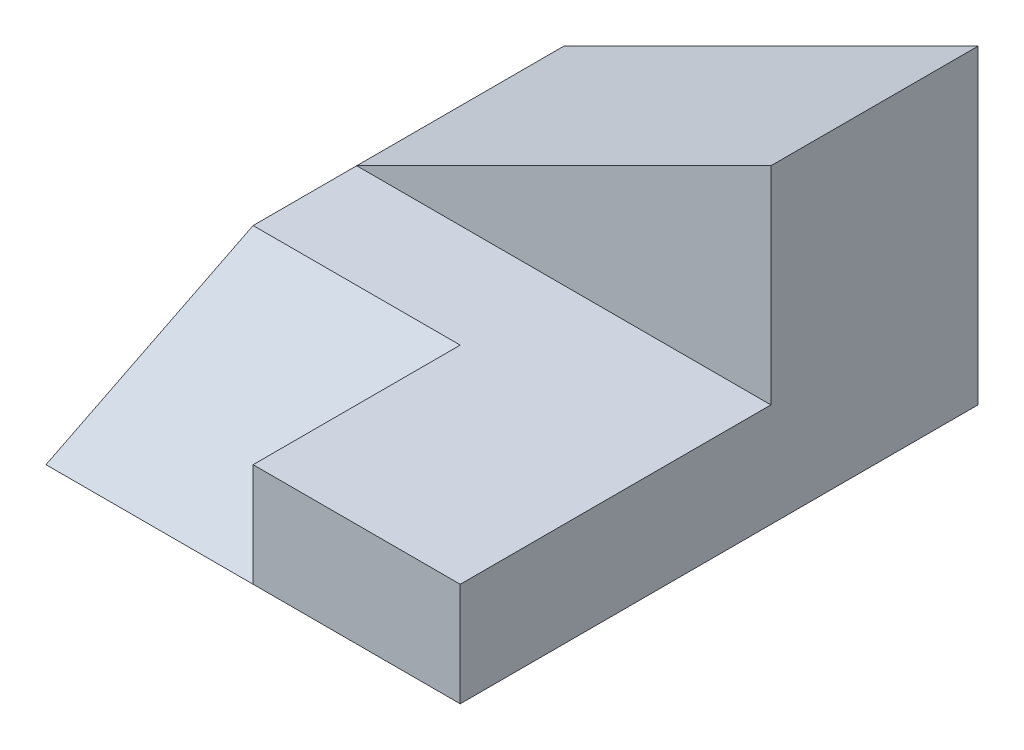
from build123d import *

# Parameters (mm, degrees)
BOSS_EXTRUDE1_DEPTH = 40
CUT_EXTRUDE6_DEPTH  = 50
CUT_EXTRUDE7_DEPTH  = 20


with BuildPart() as part:
    # Sketch1 → Boss-Extrude1 (new body)
    with BuildSketch(Plane(origin=(0, 0, 0), x_dir=(0, 0, -1), z_dir=(1, 0, 0))):
        Polygon((25, 0), (-25, 0), (-25, 10), (5, 10), (5, 30), (25, 30), align=None)
    extrude(amount=-BOSS_EXTRUDE1_DEPTH)

    # Sketch3 → Cut-Extrude6 (cut)
    with BuildSketch(Plane.XY.offset(-5)):
        Polygon((0, 30), (-40, 10), (-40, 30), align=None)
    extrude(amount=-CUT_EXTRUDE6_DEPTH, mode=Mode.SUBTRACT)

    # Sketch5 → Cut-Extrude7 (cut)
    with BuildSketch(Plane.ZY.offset(40)):
        Polygon((25, 10), (5, 10), (25, 0), align=None)
    extrude(amount=-CUT_EXTRUDE7_DEPTH, mode=Mode.SUBTRACT)


solid = part.part
